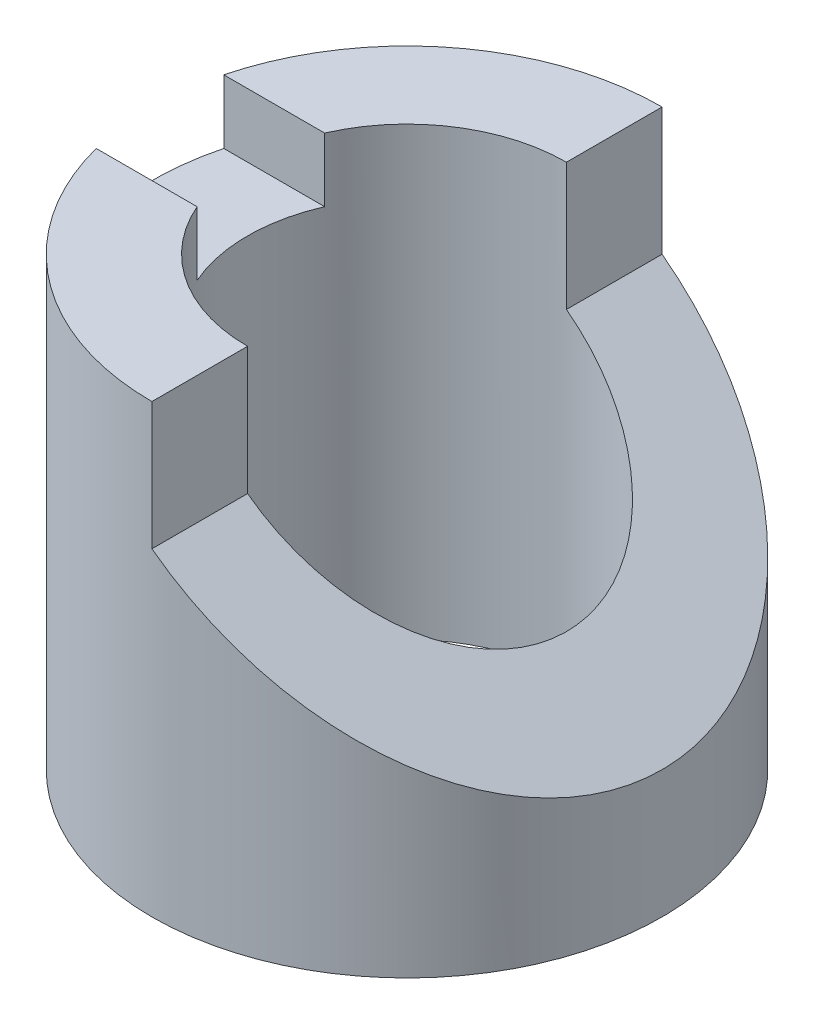
from build123d import *

# Parameters (mm, degrees)
BOSS_EXTRUDE1_DEPTH     = 70
BOSS_EXTRUDE2_DEPTH     = 60
CUT_EXTRUDE1_DEPTH      = 91
CUT_EXTRUDE1_DEPTH_BACK = 91


with BuildPart() as part:
    # Sketch1 → Boss-Extrude1 (new body)
    with BuildSketch(Plane(origin=(0, 0, 0), x_dir=(1, 0, 0), z_dir=(0, 1, 0))):
        with BuildLine():
            Line((-38.729833462, 10), (-22.912878475, 10))
            ThreePointArc((-22.912878475, 10), (25, 0), (-22.912878475, -10))
            Line((-22.912878475, -10), (-38.729833462, -10))
            ThreePointArc((-38.729833462, -10), (40, 0), (-38.729833462, 10))
        make_face()
    extrude(amount=BOSS_EXTRUDE1_DEPTH)

    # Sketch1_3 → Boss-Extrude2 (add)
    with BuildSketch(Plane(origin=(0, 0, 0), x_dir=(1, 0, 0), z_dir=(0, 1, 0))):
        with BuildLine():
            Line((-22.912878475, 10), (-38.729833462, 10))
            ThreePointArc((-38.729833462, 10), (-40, 0), (-38.729833462, -10))
            Line((-38.729833462, -10), (-22.912878475, -10))
            ThreePointArc((-22.912878475, -10), (-25, 0), (-22.912878475, 10))
        make_face()
    extrude(amount=BOSS_EXTRUDE2_DEPTH)

    # Sketch4 → Cut-Extrude1 (cut, two sides: drawn at the far end of the back side and taken through both)
    with BuildSketch(Plane.XY.offset(-CUT_EXTRUDE1_DEPTH_BACK)):
        Polygon((0, 70), (0, 50), (40, 20), (40, 70), align=None)
    extrude(amount=CUT_EXTRUDE1_DEPTH + CUT_EXTRUDE1_DEPTH_BACK, mode=Mode.SUBTRACT)


solid = part.part
